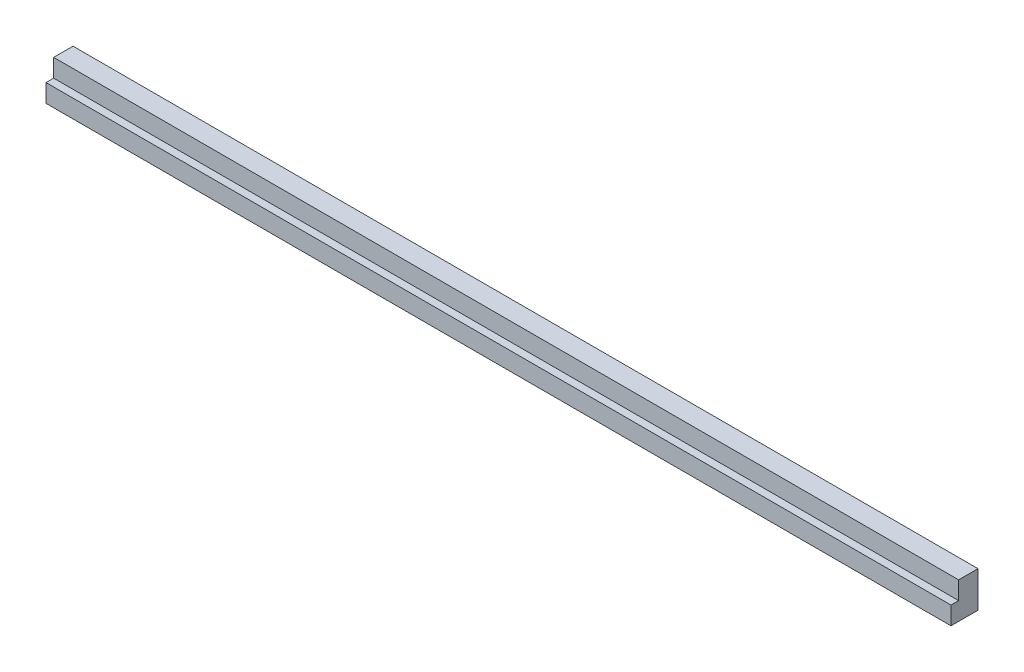
from build123d import *

# Parameters (mm, degrees)
ESQUISSE1_W        = 1005
ESQUISSE1_H        = 40
BOSS_EXTRU_1_DEPTH = 21.5
ESQUISSE2_W        = 1005
ESQUISSE2_H        = 20
BOSS_EXTRU_2_DEPTH = 8.5


with BuildPart() as part:
    # Esquisse1 → Boss.-Extru.1 (new body)
    with BuildSketch(Plane.XY):
        with Locations((138.5, -181)):
            Rectangle(ESQUISSE1_W, ESQUISSE1_H)
    extrude(amount=BOSS_EXTRU_1_DEPTH)

    # Esquisse2 → Boss.-Extru.2 (add)
    with BuildSketch(Plane.XY.offset(21.5)):
        with Locations((138.5, -191)):
            Rectangle(ESQUISSE2_W, ESQUISSE2_H)
    extrude(amount=BOSS_EXTRU_2_DEPTH)


solid = part.part
